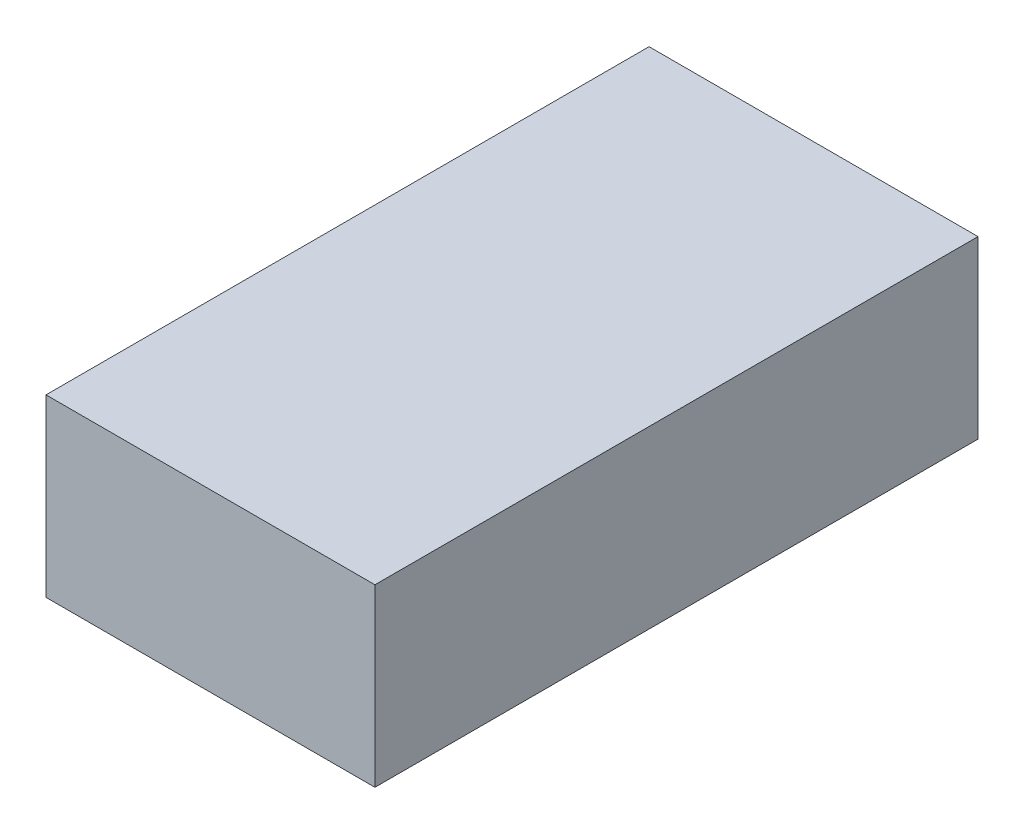
from build123d import *

# Parameters (mm, degrees)
SKETCH1_W           = 30
SKETCH1_H           = 55
BOSS_EXTRUDE1_DEPTH = 16


with BuildPart() as part:
    # Sketch1 → Boss-Extrude1 (new body)
    with BuildSketch(Plane(origin=(0, 0, 0), x_dir=(1, 0, 0), z_dir=(0, 1, 0))):
        with Locations((47.80866102, -6.595204738)):
            Rectangle(SKETCH1_W, SKETCH1_H)
    extrude(amount=BOSS_EXTRUDE1_DEPTH)


solid = part.part
